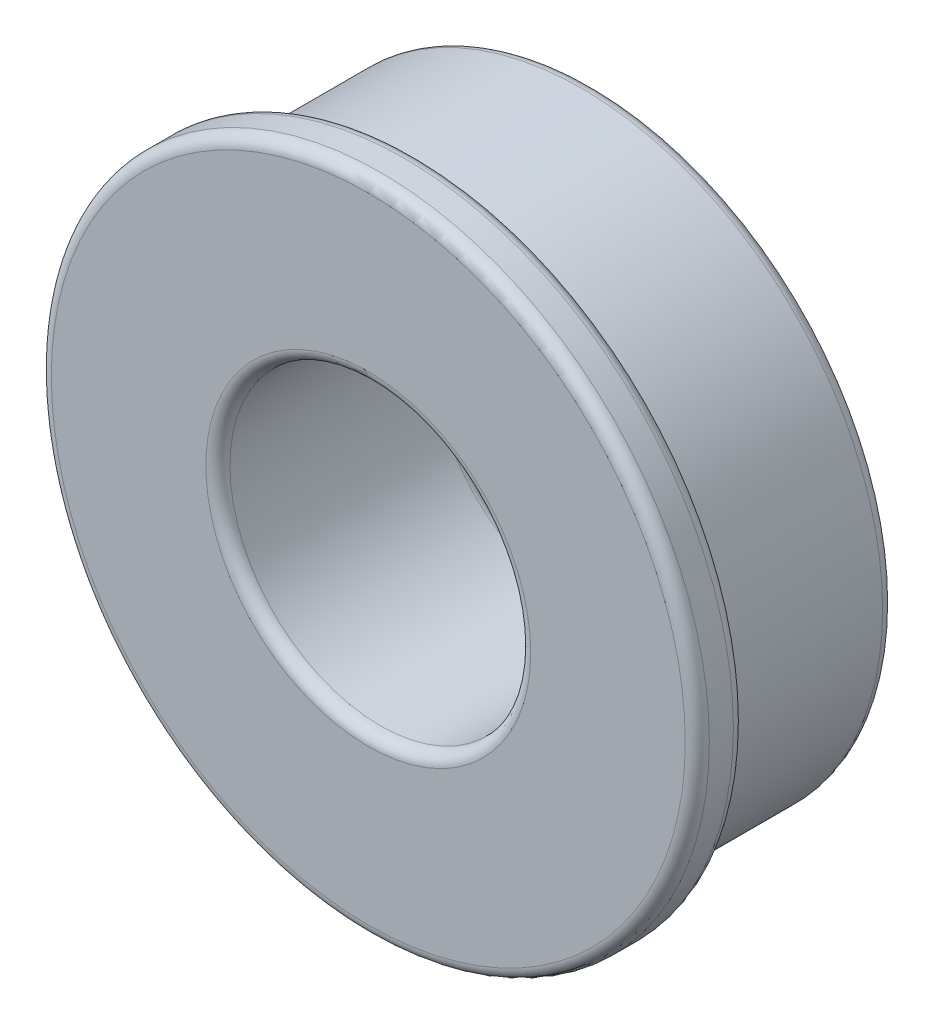
from build123d import *

# Parameters (mm, degrees)
SKETCH1_R           = 6.35
BOSS_EXTRUDE1_DEPTH = 4.7625
SKETCH2_R           = 6.9453125
BOSS_EXTRUDE2_DEPTH = 1.016
SKETCH3_R           = 3.175
CUT_EXTRUDE1_DEPTH  = 4.7625
FILLET1_R           = 0.254


with BuildPart() as part:
    # Sketch1 → Boss-Extrude1 (new body)
    with BuildSketch(Plane.XY):
        Circle(SKETCH1_R)
    extrude(amount=BOSS_EXTRUDE1_DEPTH)

    # Sketch2 → Boss-Extrude2 (add)
    with BuildSketch(Plane.XY.offset(4.7625)):
        Circle(SKETCH2_R)
    extrude(amount=-BOSS_EXTRUDE2_DEPTH)

    # Sketch3 → Cut-Extrude1 (cut)
    with BuildSketch(Plane.XY.offset(4.7625)):
        Circle(SKETCH3_R)
    extrude(amount=-CUT_EXTRUDE1_DEPTH, mode=Mode.SUBTRACT)

    # Fillet1
    fillet1_edges = [part.edges().sort_by_distance(p)[0] for p in [
        (-3.175, 0, 4.7625),
        (-3.175, 0, 0),
        (-6.35, 0, 0),
        (-6.35, 0, 3.7465),
        (-6.9453125, 0, 3.7465),
        (-6.9453125, 0, 4.7625),
    ]]
    fillet(fillet1_edges, radius=FILLET1_R)


solid = part.part
